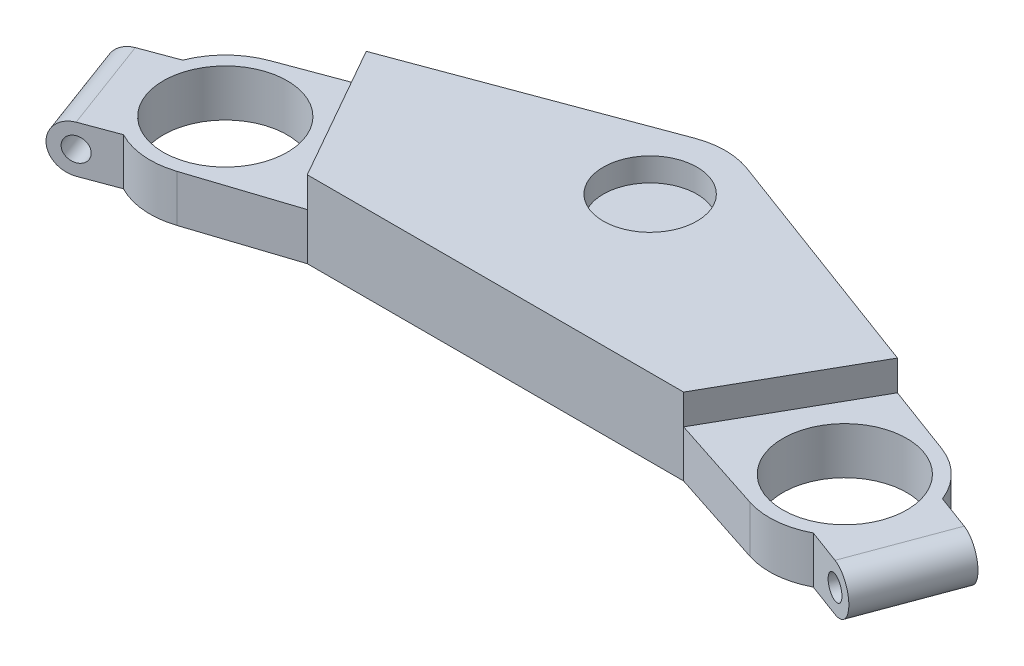
from build123d import *

# Parameters (mm, degrees)
BOSS_EXTRUDE1_DEPTH = 23
SKETCH2_R           = 18.51
CUT_EXTRUDE1_DEPTH  = 24
SKETCH3_R           = 13.985
CUT_EXTRUDE2_DEPTH  = 7
BOSS_EXTRUDE2_DEPTH = 23
CUT_EXTRUDE3_DEPTH  = 83.130091318
SKETCH10_R          = 3.5
CUT_EXTRUDE5_DEPTH  = 42
CUT_EXTRUDE8_DEPTH  = 83.130091318
CUT_EXTRUDE9_DEPTH  = 9
SKETCH15_R          = 3.5
CUT_EXTRUDE10_DEPTH = 82.477158286


with BuildPart() as part:
    # Sketch1 → Boss-Extrude1 (new body)
    with BuildSketch(Plane(origin=(0, 0, 0), x_dir=(1, 0, 0), z_dir=(0, 1, 0))):
        with BuildLine():
            Line((-100.336081003, -13.275177251), (-7.836081003, 21.091368721))
            ThreePointArc((-7.836081003, 21.091368721), (0, 22.5), (7.836081003, 21.091368721))
            Line((7.836081003, 21.091368721), (100.336081003, -13.275177251))
            ThreePointArc((100.336081003, -13.275177251), (113.745786388, -41.773742524), (85.524728129, -55.758029845))
            Line((85.524728129, -55.758029845), (56.196116933, -46.194642944))
            Line((56.196116933, -46.194642944), (-56.196116933, -46.194642944))
            Line((-56.196116933, -46.194642944), (-85.524728129, -55.758029845))
            ThreePointArc((-85.524728129, -55.758029845), (-113.745786388, -41.773742524), (-100.336081003, -13.275177251))
        make_face()
    extrude(amount=BOSS_EXTRUDE1_DEPTH)

    # Sketch2 → Cut-Extrude1 (cut, through all)
    with BuildSketch(Plane(origin=(0, 23, 0), x_dir=(1, 0, 0), z_dir=(0, 1, 0))):
        with Locations((-92.5, -34.366545972)):
            Circle(SKETCH2_R)
        with Locations((92.5, -34.366545972)):
            Circle(SKETCH2_R)
    extrude(amount=-CUT_EXTRUDE1_DEPTH, mode=Mode.SUBTRACT)

    # Sketch3 → Cut-Extrude2 (cut)
    with BuildSketch(Plane(origin=(0, 23, 0), x_dir=(1, 0, 0), z_dir=(0, 1, 0))):
        Circle(SKETCH3_R)
    extrude(amount=-CUT_EXTRUDE2_DEPTH, mode=Mode.SUBTRACT)

    # Sketch4 → Boss-Extrude2 (add)
    with BuildSketch(Plane(origin=(0, 23, 0), x_dir=(1, 0, 0), z_dir=(0, 1, 0))):
        with BuildLine():
            Line((-113.444632068, -26.146303424), (-132.192515375, -33.11170876))
            Line((-132.192515375, -33.11170876), (-121.744407372, -61.233533721))
            Line((-121.744407372, -61.233533721), (-102.996524064, -54.268128385))
            ThreePointArc((-102.996524064, -54.268128385), (-113.591368721, -42.202626974), (-113.444632068, -26.146303424))
        make_face()
        with BuildLine():
            Line((113.444632068, -26.146303424), (132.192515375, -33.11170876))
            Line((132.192515375, -33.11170876), (121.744407372, -61.233533721))
            Line((121.744407372, -61.233533721), (102.996524064, -54.268128385))
            ThreePointArc((102.996524064, -54.268128385), (113.591368721, -42.202626974), (113.444632068, -26.146303424))
        make_face()
    extrude(amount=-BOSS_EXTRUDE2_DEPTH)

    # Sketch5 → Cut-Extrude3 (cut, through all)
    with BuildSketch(Plane(origin=(5.224054002, 0, 14.060912481), x_dir=(0.937394165, 0, -0.348270267), z_dir=(0.348270267, 0, 0.937394165))):
        with BuildLine():
            Line((-135.448316262, 0), (-135.448316262, 14))
            Line((-135.448316262, 14), (-126.448316262, 14))
            ThreePointArc((-126.448316262, 14), (-133.448316262, 7), (-126.448316262, 0))
            Line((-126.448316262, 0), (-135.448316262, 0))
        make_face()
    extrude(amount=-CUT_EXTRUDE3_DEPTH, mode=Mode.SUBTRACT)

    # Sketch10 → Cut-Extrude5 (cut)
    with BuildSketch(Plane(origin=(5.224054002, 0, 14.060912481), x_dir=(0.937394165, 0, -0.348270267), z_dir=(0.348270267, 0, 0.937394165))):
        with Locations((-126.448316262, 7)):
            Circle(SKETCH10_R)
    extrude(amount=-CUT_EXTRUDE5_DEPTH, mode=Mode.SUBTRACT)

    # Sketch13 → Cut-Extrude8 (cut, through all)
    with BuildSketch(Plane(origin=(-5.224054002, 0, 14.060912481), x_dir=(0.937394165, 0, 0.348270267), z_dir=(-0.348270267, 0, 0.937394165))):
        with BuildLine():
            Line((126.448316262, 14), (135.448316262, 14))
            Line((135.448316262, 14), (135.448316262, 0))
            Line((135.448316262, 0), (126.448316262, 0))
            ThreePointArc((126.448316262, 0), (133.448316262, 7), (126.448316262, 14))
        make_face()
    extrude(amount=-CUT_EXTRUDE8_DEPTH, mode=Mode.SUBTRACT)

    # Sketch14 → Cut-Extrude9 (cut)
    with BuildSketch(Plane(origin=(0, 23, 0), x_dir=(1, 0, 0), z_dir=(0, 1, 0))):
        Polygon((-56.196116933, -46.194642944), (-93.033770242, 18.702535116), (-179.483612129, -24.236128073), (-123.538544412, -84.420295749), align=None)
        Polygon((179.483612129, -24.236128073), (123.538544412, -84.420295749), (56.196116933, -46.194642944), (93.033770242, 18.702535116), align=None)
    extrude(amount=-CUT_EXTRUDE9_DEPTH, mode=Mode.SUBTRACT)

    # Sketch15 → Cut-Extrude10 (cut, through all)
    with BuildSketch(Plane(origin=(-5.224054002, 0, 14.060912481), x_dir=(0.937394165, 0, 0.348270267), z_dir=(-0.348270267, 0, 0.937394165))):
        with Locations((126.448316262, 7)):
            Circle(SKETCH15_R)
    extrude(amount=-CUT_EXTRUDE10_DEPTH, mode=Mode.SUBTRACT)


solid = part.part
